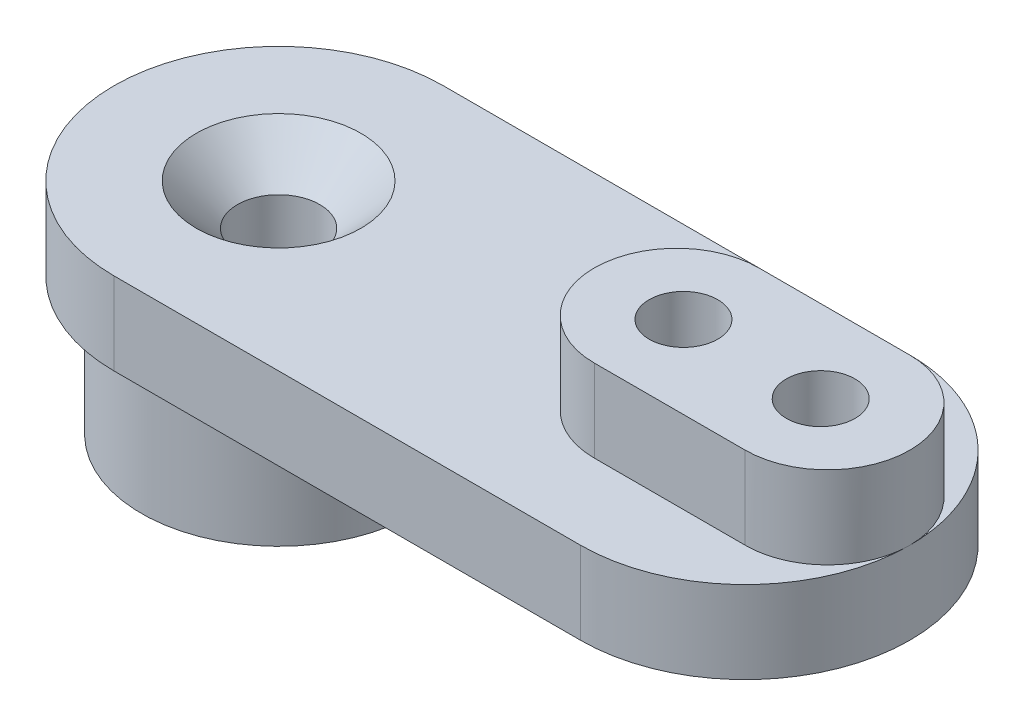
from build123d import *

# Parameters (mm, degrees)
SKETCH1_R           = 1.5
SKETCH1_R_2         = 1.25
BOSS_EXTRUDE1_DEPTH = 3
SKETCH2_R           = 1.25
BOSS_EXTRUDE2_DEPTH = 3
SKETCH3_R           = 5
SKETCH3_R_2         = 3
BOSS_EXTRUDE3_DEPTH = 5
SKETCH3_2_R         = 3
SKETCH3_2_R_2       = 1.5
BOSS_EXTRUDE4_DEPTH = 1
CHAMFER1_SIZE       = 1.5


with BuildPart() as part:
    # Sketch1 → Boss-Extrude1 (new body)
    with BuildSketch(Plane(origin=(0, 0, 0), x_dir=(1, 0, 0), z_dir=(0, 1, 0))):
        with BuildLine():
            Line((-8.5, 6), (8.5, 6))
            ThreePointArc((8.5, 6), (14.5, 0), (8.5, -6))
            Line((8.5, -6), (-8.5, -6))
            ThreePointArc((-8.5, -6), (-14.5, 0), (-8.5, 6))
        make_face()
        with Locations((-8.5, 0)):
            Circle(SKETCH1_R, mode=Mode.SUBTRACT)
        with Locations((11.25, 0)):
            Circle(SKETCH1_R_2, mode=Mode.SUBTRACT)
        with Locations((6.25, 0)):
            Circle(SKETCH1_R_2, mode=Mode.SUBTRACT)
    extrude(amount=BOSS_EXTRUDE1_DEPTH)

    # Sketch2 → Boss-Extrude2 (add)
    with BuildSketch(Plane(origin=(0, 3, 0), x_dir=(1, 0, 0), z_dir=(0, 1, 0))):
        with BuildLine():
            Line((6, 3), (11.5, 3))
            ThreePointArc((11.5, 3), (14.5, 0), (11.5, -3))
            Line((11.5, -3), (6, -3))
            ThreePointArc((6, -3), (3, 0), (6, 3))
        make_face()
        with Locations((6.25, 0)):
            Circle(SKETCH2_R, mode=Mode.SUBTRACT)
        with Locations((11.25, 0)):
            Circle(SKETCH2_R, mode=Mode.SUBTRACT)
    extrude(amount=BOSS_EXTRUDE2_DEPTH)

    # Sketch3 → Boss-Extrude3 (add)
    with BuildSketch(Plane.XZ):
        with Locations((-8.5, 0)):
            Circle(SKETCH3_R)
        with Locations((-8.5, 0)):
            Circle(SKETCH3_R_2, mode=Mode.SUBTRACT)
    extrude(amount=BOSS_EXTRUDE3_DEPTH)

    # Sketch3_2 → Boss-Extrude4 (add)
    with BuildSketch(Plane.XZ):
        with Locations((-8.5, 0)):
            Circle(SKETCH3_2_R)
        with Locations((-8.5, 0)):
            Circle(SKETCH3_2_R_2, mode=Mode.SUBTRACT)
    extrude(amount=BOSS_EXTRUDE4_DEPTH)

    # Chamfer1
    chamfer1_edges = [part.edges().sort_by_distance(p)[0] for p in [
        (-10, 3, 0),
    ]]
    chamfer(chamfer1_edges, length=CHAMFER1_SIZE)


solid = part.part
